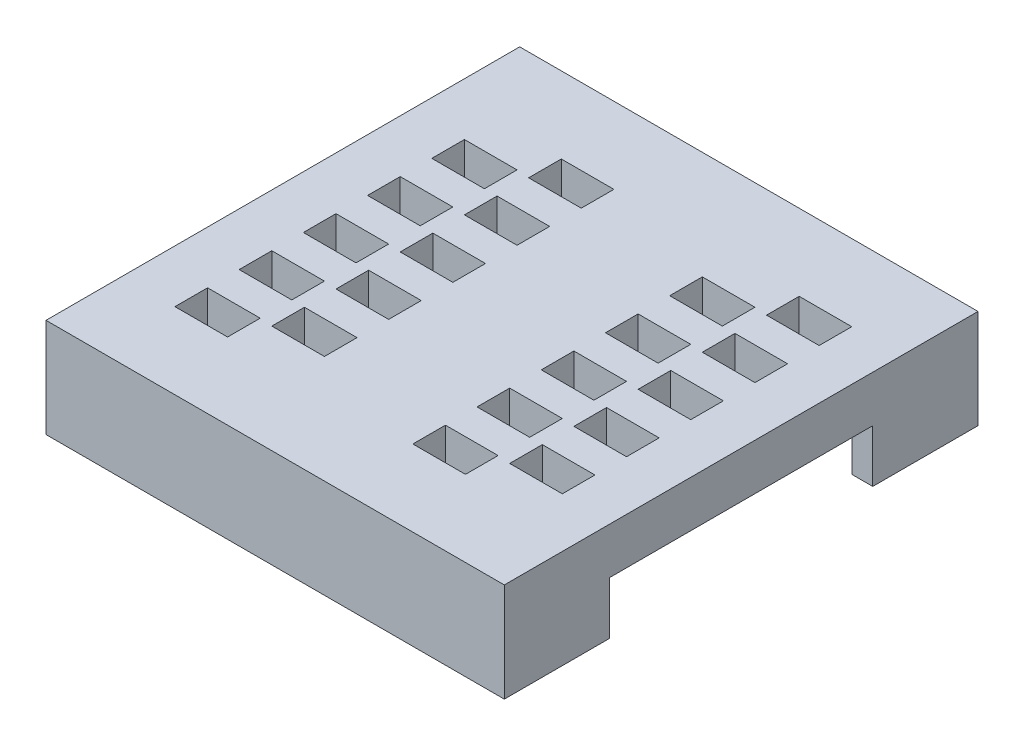
from build123d import *

# Parameters (mm, degrees)
SKETCH_1_W          = 43.5396
SKETCH_1_H          = 45
SKETCH_1_W_2        = 5
SKETCH_1_H_2        = 3.1
EXTRUDE_1_DEPTH     = 3.4
SKETCH_2_W          = 43.6316
SKETCH_2_H          = 45
SKETCH_2_RX         = 1
SKETCH_2_RY         = 1
SKETCH_2_W_2        = 5.2
SKETCH_2_H_2        = 5.2
EXTRUDE_2_DEPTH     = 1
SKETCH_6_W          = 0.092
SKETCH_6_H          = 1
CUT_EXTRUDE_2_DEPTH = 46
SKETCH_3_R          = 4
SKETCH_3_R_2        = 1
EXTRUDE_3_DEPTH     = 1.2
SKETCH_4_W          = 43.5396
SKETCH_4_H          = 45
SKETCH_4_W_2        = 39.5596
SKETCH_4_H_2        = 41.02
EXTRUDE_4_DEPTH     = 5
SKETCH_5_W          = 1.99
SKETCH_5_H          = 25
CUT_EXTRUDE_1_DEPTH = 5


with BuildPart() as part:
    # Эскиз1 → Бобышка-Вытянуть1 (new body)
    with BuildSketch(Plane(origin=(0, 0, 0), x_dir=(1, 0, 0), z_dir=(0, 1, 0))):
        with Locations((-126.7302, -82.5)):
            Rectangle(SKETCH_1_W, SKETCH_1_H)
        with Locations((-141, -96.2003)):
            Rectangle(SKETCH_1_W_2, SKETCH_1_H_2, mode=Mode.SUBTRACT)
        with Locations((-118.4, -96.2003)):
            Rectangle(SKETCH_1_W_2, SKETCH_1_H_2, mode=Mode.SUBTRACT)
        with Locations((-112.2, -93.2003)):
            Rectangle(SKETCH_1_W_2, SKETCH_1_H_2, mode=Mode.SUBTRACT)
        with Locations((-134.8, -93.2003)):
            Rectangle(SKETCH_1_W_2, SKETCH_1_H_2, mode=Mode.SUBTRACT)
        with Locations((-112.2, -87.1003)):
            Rectangle(SKETCH_1_W_2, SKETCH_1_H_2, mode=Mode.SUBTRACT)
        with Locations((-134.8, -87.1003)):
            Rectangle(SKETCH_1_W_2, SKETCH_1_H_2, mode=Mode.SUBTRACT)
        with Locations((-141, -90.1003)):
            Rectangle(SKETCH_1_W_2, SKETCH_1_H_2, mode=Mode.SUBTRACT)
        with Locations((-118.4, -90.1003)):
            Rectangle(SKETCH_1_W_2, SKETCH_1_H_2, mode=Mode.SUBTRACT)
        with Locations((-112.2, -74.9003)):
            Rectangle(SKETCH_1_W_2, SKETCH_1_H_2, mode=Mode.SUBTRACT)
        with Locations((-134.8, -74.9003)):
            Rectangle(SKETCH_1_W_2, SKETCH_1_H_2, mode=Mode.SUBTRACT)
        with Locations((-141, -77.9003)):
            Rectangle(SKETCH_1_W_2, SKETCH_1_H_2, mode=Mode.SUBTRACT)
        with Locations((-118.4, -77.9003)):
            Rectangle(SKETCH_1_W_2, SKETCH_1_H_2, mode=Mode.SUBTRACT)
        with Locations((-141, -84.0003)):
            Rectangle(SKETCH_1_W_2, SKETCH_1_H_2, mode=Mode.SUBTRACT)
        with Locations((-118.4, -84.0003)):
            Rectangle(SKETCH_1_W_2, SKETCH_1_H_2, mode=Mode.SUBTRACT)
        with Locations((-112.2, -81.0003)):
            Rectangle(SKETCH_1_W_2, SKETCH_1_H_2, mode=Mode.SUBTRACT)
        with Locations((-134.8, -81.0003)):
            Rectangle(SKETCH_1_W_2, SKETCH_1_H_2, mode=Mode.SUBTRACT)
        with Locations((-141, -71.8003)):
            Rectangle(SKETCH_1_W_2, SKETCH_1_H_2, mode=Mode.SUBTRACT)
        with Locations((-118.4, -71.8003)):
            Rectangle(SKETCH_1_W_2, SKETCH_1_H_2, mode=Mode.SUBTRACT)
        with Locations((-112.2, -68.8003)):
            Rectangle(SKETCH_1_W_2, SKETCH_1_H_2, mode=Mode.SUBTRACT)
        with Locations((-134.8, -68.8003)):
            Rectangle(SKETCH_1_W_2, SKETCH_1_H_2, mode=Mode.SUBTRACT)
    extrude(amount=EXTRUDE_1_DEPTH)

    # Эскиз2 → Бобышка-Вытянуть2 (add)
    with BuildSketch(Plane(origin=(0, 0, 0), x_dir=(1, 0, 0), z_dir=(0, 1, 0))):
        with Locations((-126.6842, -82.5)):
            Rectangle(SKETCH_2_W, SKETCH_2_H)
        with Locations(Location((-143.5, -65), (0, 0, 180))):
            Ellipse(SKETCH_2_RX, SKETCH_2_RY, mode=Mode.SUBTRACT)
        with Locations(Location((-143.5, -100), (0, 0, 180))):
            Ellipse(SKETCH_2_RX, SKETCH_2_RY, mode=Mode.SUBTRACT)
        with Locations(Location((-109.7, -65), (0, 0, 180))):
            Ellipse(SKETCH_2_RX, SKETCH_2_RY, mode=Mode.SUBTRACT)
        with Locations(Location((-109.7, -100), (0, 0, 180))):
            Ellipse(SKETCH_2_RX, SKETCH_2_RY, mode=Mode.SUBTRACT)
        with Locations((-134.8, -68.8)):
            Rectangle(SKETCH_2_W_2, SKETCH_2_H_2, mode=Mode.SUBTRACT)
        with Locations((-134.8, -74.9)):
            Rectangle(SKETCH_2_W_2, SKETCH_2_H_2, mode=Mode.SUBTRACT)
        with Locations((-134.8, -81)):
            Rectangle(SKETCH_2_W_2, SKETCH_2_H_2, mode=Mode.SUBTRACT)
        with Locations((-134.8, -87.1)):
            Rectangle(SKETCH_2_W_2, SKETCH_2_H_2, mode=Mode.SUBTRACT)
        with Locations((-134.8, -93.2003)):
            Rectangle(SKETCH_2_W_2, SKETCH_2_H_2, mode=Mode.SUBTRACT)
        with Locations((-118.4, -71.8003)):
            Rectangle(SKETCH_2_W_2, SKETCH_2_H_2, mode=Mode.SUBTRACT)
        with Locations((-118.4, -77.9003)):
            Rectangle(SKETCH_2_W_2, SKETCH_2_H_2, mode=Mode.SUBTRACT)
        with Locations((-118.4, -84.0003)):
            Rectangle(SKETCH_2_W_2, SKETCH_2_H_2, mode=Mode.SUBTRACT)
        with Locations((-118.4, -90.1003)):
            Rectangle(SKETCH_2_W_2, SKETCH_2_H_2, mode=Mode.SUBTRACT)
        with Locations((-118.4, -96.2003)):
            Rectangle(SKETCH_2_W_2, SKETCH_2_H_2, mode=Mode.SUBTRACT)
    extrude(amount=-EXTRUDE_2_DEPTH)

    # Эскиз6 → Вырез-Вытянуть2 (cut, through all)
    with BuildSketch(Plane(origin=(0, 0, 60), x_dir=(-1, 0, 0), z_dir=(0, 0, -1))):
        with Locations((104.9144, -0.5)):
            Rectangle(SKETCH_6_W, SKETCH_6_H)
    extrude(amount=-CUT_EXTRUDE_2_DEPTH, mode=Mode.SUBTRACT)

    # Эскиз3 → Бобышка-Вытянуть3 (add)
    with BuildSketch(Plane.XZ.offset(1)):
        with Locations((-143.5, 100)):
            Circle(SKETCH_3_R)
        with Locations((-143.5, 100)):
            Circle(SKETCH_3_R_2, mode=Mode.SUBTRACT)
        with Locations((-109.7, 100)):
            Circle(SKETCH_3_R)
        with Locations((-109.7, 100)):
            Circle(SKETCH_3_R_2, mode=Mode.SUBTRACT)
        with Locations((-143.5, 65)):
            Circle(SKETCH_3_R)
        with Locations((-143.5, 65)):
            Circle(SKETCH_3_R_2, mode=Mode.SUBTRACT)
        with Locations((-109.7, 65)):
            Circle(SKETCH_3_R)
        with Locations((-109.7, 65)):
            Circle(SKETCH_3_R_2, mode=Mode.SUBTRACT)
    extrude(amount=EXTRUDE_3_DEPTH)

    # Эскиз4 → Бобышка-Вытянуть4 (add)
    with BuildSketch(Plane.XZ.offset(1)):
        with Locations((-126.7302, 82.5)):
            Rectangle(SKETCH_4_W, SKETCH_4_H)
        with Locations((-126.7302, 82.5)):
            Rectangle(SKETCH_4_W_2, SKETCH_4_H_2, mode=Mode.SUBTRACT)
    extrude(amount=EXTRUDE_4_DEPTH)

    # Эскиз5 → Вырез-Вытянуть1 (cut)
    with BuildSketch(Plane.XZ.offset(6)):
        with Locations((-147.505, 82.5)):
            Rectangle(SKETCH_5_W, SKETCH_5_H)
        with Locations((-105.9554, 82.5)):
            Rectangle(SKETCH_5_W, SKETCH_5_H)
    extrude(amount=-CUT_EXTRUDE_1_DEPTH, mode=Mode.SUBTRACT)


solid = part.part
